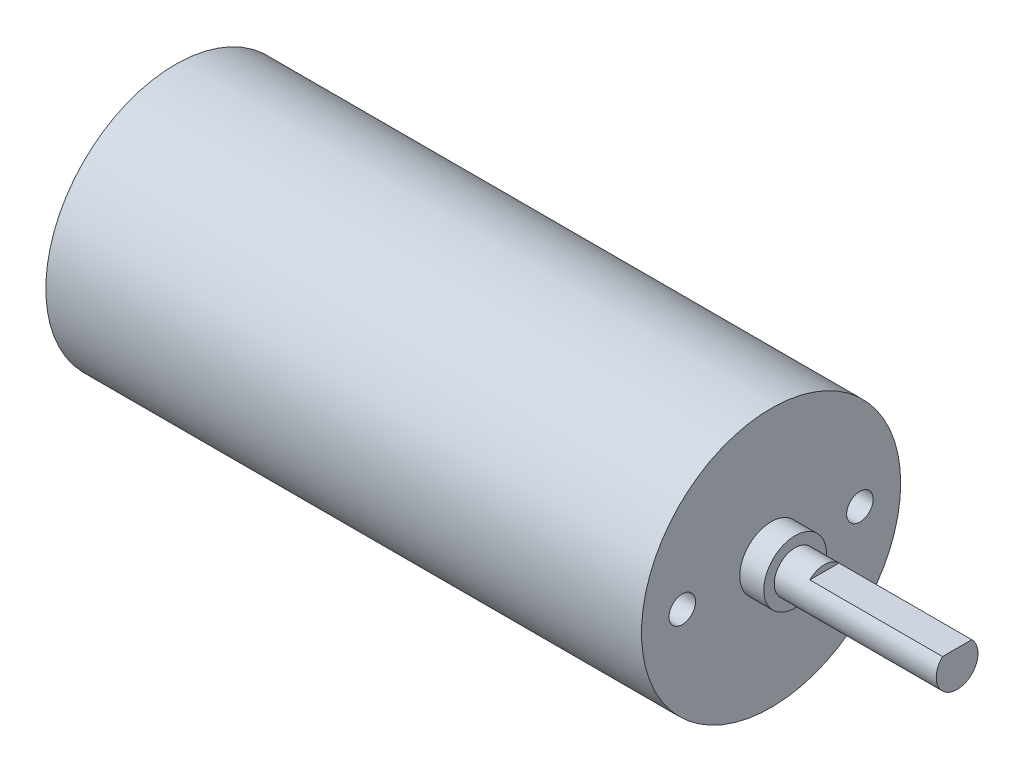
from build123d import *

# Parameters (mm, degrees)
SKETCH1_R           = 12.4
BOSS_EXTRUDE1_DEPTH = 57
SKETCH2_R           = 3
BOSS_EXTRUDE2_DEPTH = 2.3
SKETCH3_R           = 2
BOSS_EXTRUDE3_DEPTH = 15.5
SKETCH4_R           = 1.27
CUT_EXTRUDE1_DEPTH  = 5
CUT_EXTRUDE3_DEPTH  = 12.7


with BuildPart() as part:
    # Sketch1 → Boss-Extrude1 (new body)
    with BuildSketch(Plane(origin=(0, 0, 0), x_dir=(0, 0, -1), z_dir=(1, 0, 0))):
        Circle(SKETCH1_R)
    extrude(amount=-BOSS_EXTRUDE1_DEPTH)

    # Sketch2 → Boss-Extrude2 (add)
    with BuildSketch(Plane(origin=(0, 0, 0), x_dir=(0, 0, -1), z_dir=(1, 0, 0))):
        Circle(SKETCH2_R)
    extrude(amount=BOSS_EXTRUDE2_DEPTH)

    # Sketch3 → Boss-Extrude3 (add)
    with BuildSketch(Plane(origin=(2.3, 0, 0), x_dir=(0, 0, -1), z_dir=(1, 0, 0))):
        Circle(SKETCH3_R)
    extrude(amount=BOSS_EXTRUDE3_DEPTH)

    # Sketch4 → Cut-Extrude1 (cut)
    with BuildSketch(Plane(origin=(0, 0, 0), x_dir=(0, 0, -1), z_dir=(1, 0, 0))):
        with Locations((8.5, 0)):
            Circle(SKETCH4_R)
        with Locations((-8.5, 0)):
            Circle(SKETCH4_R)
    extrude(amount=-CUT_EXTRUDE1_DEPTH, mode=Mode.SUBTRACT)

    # Sketch5 → Cut-Extrude3 (cut)
    with BuildSketch(Plane(origin=(17.8, 0, 0), x_dir=(0, 0, -1), z_dir=(1, 0, 0))):
        with BuildLine():
            Line((0, 1.429), (-1.399270882, 1.429))
            ThreePointArc((-1.399270882, 1.429), (0, 2), (1.399270882, 1.429))
            Line((1.399270882, 1.429), (0, 1.429))
        make_face()
    extrude(amount=-CUT_EXTRUDE3_DEPTH, mode=Mode.SUBTRACT)


solid = part.part
